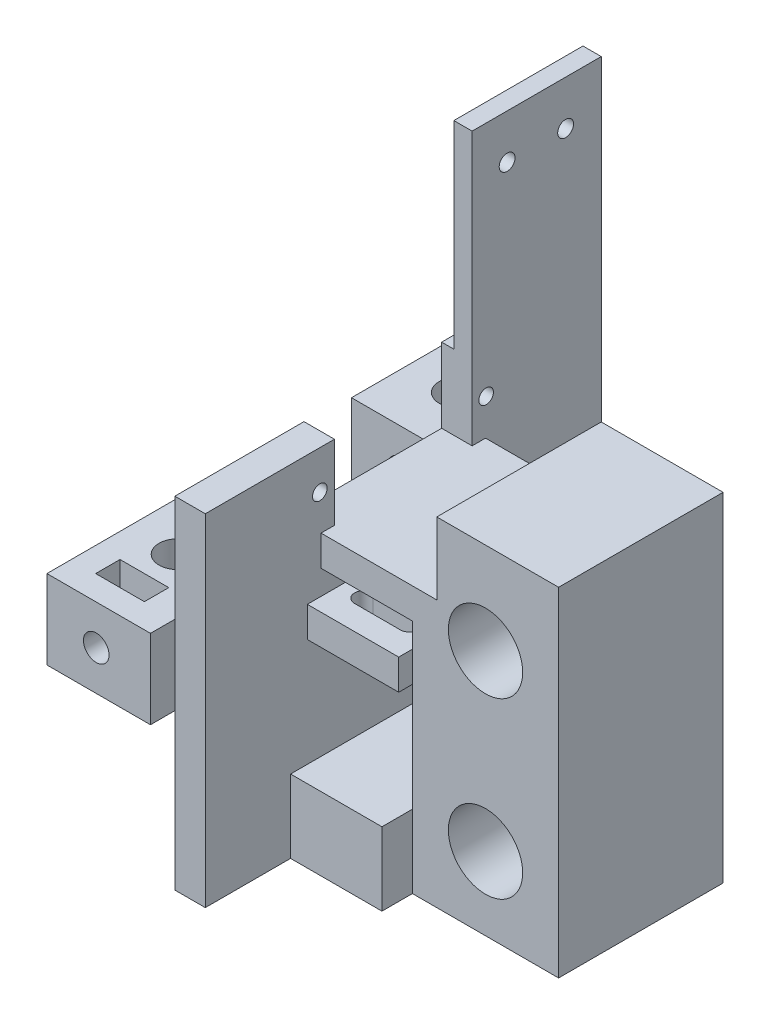
from build123d import *

# Parameters (mm, degrees)
SKETCH1_W                = 24
SKETCH1_H                = 52.5
SKETCH1_R                = 6.1
BOSS_EXTRUDE1_DEPTH      = 13.5
BOSS_EXTRUDE2_DEPTH      = 3
BOSS_EXTRUDE2_DEPTH_BACK = 2
SKETCH3_W                = 27
SKETCH3_H                = 18
BOSS_EXTRUDE3_DEPTH      = 15
SKETCH4_W                = 32
SKETCH4_H                = 12
CUT_EXTRUDE2_DEPTH       = 18
SKETCH6_W                = 65
SKETCH6_H                = 56
BOSS_EXTRUDE4_DEPTH      = 22
SKETCH7_R                = 3.1
CUT_EXTRUDE3_DEPTH       = 57
SKETCH8_W                = 17
SKETCH8_H                = 65
CUT_EXTRUDE4_DEPTH       = 17.5
SKETCH11_W               = 22.6
SKETCH11_H               = 12.25
CUT_EXTRUDE6_DEPTH       = 5
SKETCH12_W               = 17
SKETCH12_H               = 27
CUT_EXTRUDE7_DEPTH       = 39.5
SKETCH13_W               = 17
SKETCH13_H               = 65
CUT_EXTRUDE8_DEPTH       = 25.5
SKETCH16_W               = 15
SKETCH16_H               = 27
CUT_EXTRUDE9_DEPTH       = 6
SKETCH17_W               = 15
SKETCH17_H               = 12
BOSS_EXTRUDE5_DEPTH      = 5
BOSS_EXTRUDE5_DEPTH_BACK = 32
SKETCH19_W               = 21
SKETCH19_H               = 27
BOSS_EXTRUDE6_DEPTH      = 3.05
SKETCH20_W               = 1
SKETCH20_H               = 11.8
CUT_EXTRUDE11_DEPTH      = 47
SKETCH21_R               = 1.2
CUT_EXTRUDE12_DEPTH      = 10
SKETCH23_W               = 17
SKETCH23_H               = 13
BOSS_EXTRUDE7_DEPTH      = 4
SKETCH24_W               = 17
SKETCH24_H               = 13
BOSS_EXTRUDE8_DEPTH      = 4
SKETCH25_R               = 2.1
CUT_EXTRUDE14_DEPTH      = 74
SKETCH26_W               = 8
SKETCH26_H               = 4
CUT_EXTRUDE15_DEPTH      = 39.5
SKETCH27_W               = 3
SKETCH27_H               = 21.2
BOSS_EXTRUDE9_DEPTH      = 32.5
SKETCH28_R               = 1.3
CUT_EXTRUDE16_DEPTH      = 43


with BuildPart() as part:
    # Sketch1 → Boss-Extrude1 (new body, symmetric)
    with BuildSketch(Plane.XY):
        with Locations((12, 0)):
            Rectangle(SKETCH1_W, SKETCH1_H)
        with Locations((12, 14.25)):
            Circle(SKETCH1_R, mode=Mode.SUBTRACT)
        with Locations((12, -14.25)):
            Circle(SKETCH1_R, mode=Mode.SUBTRACT)
    extrude(amount=BOSS_EXTRUDE1_DEPTH, both=True)

    # Sketch2 → Boss-Extrude2 (add, two sides)
    with BuildSketch(Plane(origin=(0, 5.5, 0), x_dir=(1, 0, 0), z_dir=(0, 1, 0))) as boss_extrude2_sk:
        Polygon((-4, -7), (0, -7), (0, -15.75), (-15, -15.75), (-15, -7), (-11, -7), align=None)
        with BuildLine():
            Line((-11.25, -8.75), (-3.75, -8.75))
            ThreePointArc((-3.75, -8.75), (-2.25, -10.25), (-3.75, -11.75))
            Line((-3.75, -11.75), (-11.25, -11.75))
            ThreePointArc((-11.25, -11.75), (-12.75, -10.25), (-11.25, -8.75))
        make_face(mode=Mode.SUBTRACT)
        Polygon((-4, 7), (-11, 7), (-15, 7), (-15, 15.75), (0, 15.75), (0, 7), align=None)
        with BuildLine():
            ThreePointArc((-3.75, 8.75), (-2.25, 10.25), (-3.75, 11.75))
            Line((-3.75, 11.75), (-11.25, 11.75))
            ThreePointArc((-11.25, 11.75), (-12.75, 10.25), (-11.25, 8.75))
            Line((-11.25, 8.75), (-3.75, 8.75))
        make_face(mode=Mode.SUBTRACT)
    extrude(amount=BOSS_EXTRUDE2_DEPTH)
    extrude(boss_extrude2_sk.sketch, amount=-BOSS_EXTRUDE2_DEPTH_BACK)

    # Sketch3 → Boss-Extrude3 (add)
    with BuildSketch(Plane.ZY):
        Polygon((13.5, 26.25), (-13.5, 26.25), (-13.5, 12.5), (-8.75, 12.5), (8.75, 12.5), (13.5, 12.5), align=None)
        Polygon((8.75, 12.5), (-8.75, 12.5), (-8.75, 8.5), (-7, 8.5), (-7, 5.5), (7, 5.5), (7, 8.5), (8.75, 8.5), align=None)
        with Locations((0, -17.25)):
            Rectangle(SKETCH3_W, SKETCH3_H)
    extrude(amount=BOSS_EXTRUDE3_DEPTH)

    # Sketch4 → Cut-Extrude2 (cut)
    with BuildSketch(Plane.ZY.offset(15)):
        with Locations((0, 23.5)):
            Rectangle(SKETCH4_W, SKETCH4_H)
    extrude(amount=-CUT_EXTRUDE2_DEPTH, mode=Mode.SUBTRACT)

    # Sketch6 → Boss-Extrude4 (add)
    with BuildSketch(Plane.ZY.offset(15)):
        with Locations((0, 1.75)):
            Rectangle(SKETCH6_W, SKETCH6_H)
    extrude(amount=BOSS_EXTRUDE4_DEPTH)

    # Sketch7 → Cut-Extrude3 (cut, through all)
    with BuildSketch(Plane(origin=(0, 29.75, 0), x_dir=(1, 0, 0), z_dir=(0, 1, 0))):
        with Locations((-29, 23)):
            Circle(SKETCH7_R)
        with Locations((-29, -23)):
            Circle(SKETCH7_R)
    extrude(amount=-CUT_EXTRUDE3_DEPTH, mode=Mode.SUBTRACT)

    # Sketch8 → Cut-Extrude4 (cut)
    with BuildSketch(Plane(origin=(0, 29.75, 0), x_dir=(1, 0, 0), z_dir=(0, 1, 0))):
        with Locations((-28.5, 0)):
            Rectangle(SKETCH8_W, SKETCH8_H)
    extrude(amount=-CUT_EXTRUDE4_DEPTH, mode=Mode.SUBTRACT)

    # Sketch11 → Cut-Extrude6 (cut)
    with BuildSketch(Plane.ZY.offset(20)):
        with Locations((0, 23.625)):
            Rectangle(SKETCH11_W, SKETCH11_H)
    extrude(amount=-CUT_EXTRUDE6_DEPTH, mode=Mode.SUBTRACT)

    # Sketch12 → Cut-Extrude7 (cut, through all)
    with BuildSketch(Plane(origin=(0, 12.25, 0), x_dir=(1, 0, 0), z_dir=(0, 1, 0))):
        with Locations((-28.5, 0)):
            Rectangle(SKETCH12_W, SKETCH12_H)
    extrude(amount=-CUT_EXTRUDE7_DEPTH, mode=Mode.SUBTRACT)

    # Sketch13 → Cut-Extrude8 (cut)
    with BuildSketch(Plane.XZ.offset(26.25)):
        with Locations((-28.5, 0)):
            Rectangle(SKETCH13_W, SKETCH13_H)
    extrude(amount=-CUT_EXTRUDE8_DEPTH, mode=Mode.SUBTRACT)

    # Sketch16 → Cut-Extrude9 (cut)
    with BuildSketch(Plane(origin=(0, -8.25, 0), x_dir=(1, 0, 0), z_dir=(0, 1, 0))):
        with Locations((-7.5, 0)):
            Rectangle(SKETCH16_W, SKETCH16_H)
    extrude(amount=-CUT_EXTRUDE9_DEPTH, mode=Mode.SUBTRACT)

    # Sketch17 → Boss-Extrude5 (add, two sides)
    with BuildSketch(Plane(origin=(0, 0, -13.5), x_dir=(-1, 0, 0), z_dir=(0, 0, -1))) as boss_extrude5_sk:
        with Locations((7.5, -20.25)):
            Rectangle(SKETCH17_W, SKETCH17_H)
    extrude(amount=BOSS_EXTRUDE5_DEPTH)
    extrude(boss_extrude5_sk.sketch, amount=-BOSS_EXTRUDE5_DEPTH_BACK)

    # Sketch19 → Boss-Extrude6 (add)
    with BuildSketch(Plane(origin=(0, 26.25, 0), x_dir=(1, 0, 0), z_dir=(0, 1, 0))):
        with Locations((13.5, 0)):
            Rectangle(SKETCH19_W, SKETCH19_H)
    extrude(amount=BOSS_EXTRUDE6_DEPTH)

    # Sketch20 → Cut-Extrude11 (cut, through all)
    with BuildSketch(Plane.XY.offset(13.5)):
        with Locations((3.5, 23.4)):
            Rectangle(SKETCH20_W, SKETCH20_H)
    extrude(amount=-CUT_EXTRUDE11_DEPTH, mode=Mode.SUBTRACT)

    # Sketch21 → Cut-Extrude12 (cut)
    with BuildSketch(Plane(origin=(-15, 0, 0), x_dir=(0, 0, -1), z_dir=(1, 0, 0))):
        with Locations((-13.7, 23.4)):
            Circle(SKETCH21_R)
        with Locations((13.6, 23.4)):
            Circle(SKETCH21_R)
    extrude(amount=-CUT_EXTRUDE12_DEPTH, mode=Mode.SUBTRACT)

    # Sketch23 → Boss-Extrude7 (add)
    with BuildSketch(Plane(origin=(0, 0, -32.5), x_dir=(-1, 0, 0), z_dir=(0, 0, -1))):
        with Locations((28.5, 5.75)):
            Rectangle(SKETCH23_W, SKETCH23_H)
    extrude(amount=BOSS_EXTRUDE7_DEPTH)

    # Sketch24 → Boss-Extrude8 (add)
    with BuildSketch(Plane.XY.offset(32.5)):
        with Locations((-28.5, 5.75)):
            Rectangle(SKETCH24_W, SKETCH24_H)
    extrude(amount=BOSS_EXTRUDE8_DEPTH)

    # Sketch25 → Cut-Extrude14 (cut, through all)
    with BuildSketch(Plane(origin=(0, 0, -36.5), x_dir=(-1, 0, 0), z_dir=(0, 0, -1))):
        with Locations((28.902210775, 5.75)):
            Circle(SKETCH25_R)
    extrude(amount=-CUT_EXTRUDE14_DEPTH, mode=Mode.SUBTRACT)

    # Sketch26 → Cut-Extrude15 (cut, through all)
    with BuildSketch(Plane(origin=(0, 12.25, 0), x_dir=(1, 0, 0), z_dir=(0, 1, 0))):
        with Locations((-29, -30.5)):
            Rectangle(SKETCH26_W, SKETCH26_H)
        with Locations((-29, 30.5)):
            Rectangle(SKETCH26_W, SKETCH26_H)
    extrude(amount=-CUT_EXTRUDE15_DEPTH, mode=Mode.SUBTRACT)

    # Sketch27 → Boss-Extrude9 (add)
    with BuildSketch(Plane(origin=(0, 29.75, 0), x_dir=(1, 0, 0), z_dir=(0, 1, 0))):
        with Locations((-16.5, 21.9)):
            Rectangle(SKETCH27_W, SKETCH27_H)
    extrude(amount=BOSS_EXTRUDE9_DEPTH)

    # Sketch28 → Cut-Extrude16 (cut, through all)
    with BuildSketch(Plane.ZY.offset(18)):
        with Locations((-26.65, 54.95)):
            Circle(SKETCH28_R)
        with Locations((-17.05, 54.95)):
            Circle(SKETCH28_R)
    extrude(amount=-CUT_EXTRUDE16_DEPTH, mode=Mode.SUBTRACT)


solid = part.part
